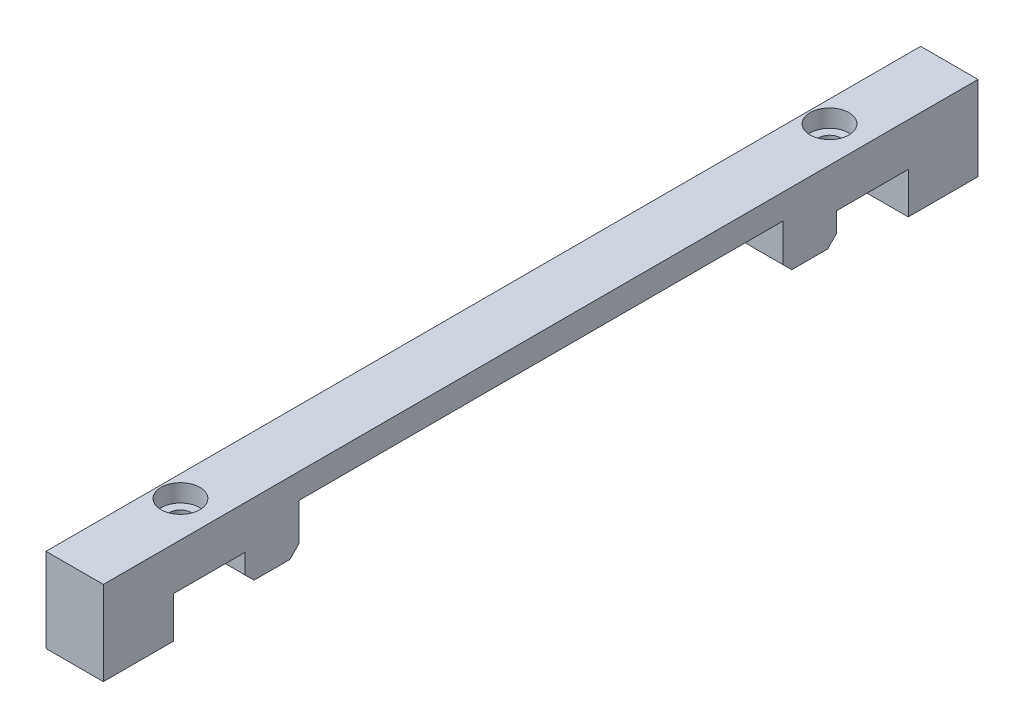
from build123d import *

# Parameters (mm, degrees)
SKETCH1_W                        = 8.128
SKETCH1_H                        = 127
BOSS_EXTRUDE1_DEPTH              = 18.288
SKETCH2_W                        = 8.128
SKETCH2_H                        = 104.14
CUT_EXTRUDE1_DEPTH               = 8.128
SKETCH4_W                        = 8.128
SKETCH4_H                        = 10.16
CUT_EXTRUDE2_DEPTH               = 4.064
SKETCH5_W                        = 8.128
SKETCH5_H                        = 34.29
CUT_EXTRUDE4_DEPTH               = 6.604
CBORE_FOR_M2_5_SHCS1_D           = 3.1
CBORE_FOR_M2_5_SHCS1_CBORE_D     = 5.5
CBORE_FOR_M2_5_SHCS1_CBORE_DEPTH = 2.5
CHAMFER1_SIZE                    = 1.27
SKETCH17_W                       = 8.128
SKETCH17_H                       = 127
CUT_EXTRUDE5_DEPTH               = 6.35
SKETCH18_W                       = 8.128
SKETCH18_H                       = 1.546440773
CUT_EXTRUDE6_DEPTH               = 12.938
SKETCH19_W                       = 8.128
SKETCH19_H                       = 1.507728281
CUT_EXTRUDE7_DEPTH               = 12.938


with BuildPart() as part:
    # Sketch1 → Boss-Extrude1 (new body)
    with BuildSketch(Plane(origin=(0, 0, 0), x_dir=(1, 0, 0), z_dir=(0, 1, 0))):
        Rectangle(SKETCH1_W, SKETCH1_H)
    extrude(amount=BOSS_EXTRUDE1_DEPTH)

    # Sketch2 → Cut-Extrude1 (cut)
    with BuildSketch(Plane.XZ):
        Rectangle(SKETCH2_W, SKETCH2_H)
    extrude(amount=-CUT_EXTRUDE1_DEPTH, mode=Mode.SUBTRACT)

    # Sketch4 → Cut-Extrude2 (cut)
    with BuildSketch(Plane.XZ.offset(-8.128)):
        with Locations((0, -46.99)):
            Rectangle(SKETCH4_W, SKETCH4_H)
    cut_extrude2 = extrude(amount=-CUT_EXTRUDE2_DEPTH, mode=Mode.SUBTRACT)

    # Sketch5 → Cut-Extrude4 (cut)
    with BuildSketch(Plane.XZ.offset(-8.128)):
        with Locations((0, -17.145)):
            Rectangle(SKETCH5_W, SKETCH5_H)
    cut_extrude4 = extrude(amount=-CUT_EXTRUDE4_DEPTH, mode=Mode.SUBTRACT)

    # CBORE for M2.5 SHCS1 (through all)
    with Locations(Plane(origin=(0, 18.288, 0), x_dir=(1, 0, 0), z_dir=(0, 1, 0))):
        with Locations((-1.016, 45.99)):
            cbore_for_m2_5_shcs1 = CounterBoreHole(CBORE_FOR_M2_5_SHCS1_D / 2, CBORE_FOR_M2_5_SHCS1_CBORE_D / 2, CBORE_FOR_M2_5_SHCS1_CBORE_DEPTH)

    # Mirror1: Cut-Extrude2, Cut-Extrude4 across plane
    add(cut_extrude2.mirror(Plane(origin=(4.064, 14.732, 0), x_dir=(1, 0, 0), z_dir=(0, 0, 1))), mode=Mode.SUBTRACT)
    add(cut_extrude4.mirror(Plane(origin=(4.064, 14.732, 0), x_dir=(1, 0, 0), z_dir=(0, 0, 1))), mode=Mode.SUBTRACT)

    # Mirror2: CBORE for M2.5 SHCS1 across plane
    add(cbore_for_m2_5_shcs1.mirror(Plane.XY), mode=Mode.SUBTRACT)

    # Sketch15 → Ø1.0mm Dowel Hole1 (revolve, cut)
    with BuildSketch(Plane(origin=(0, 0, -57.785), x_dir=(0, 0, -1), z_dir=(1, 0, 0))):
        Polygon((0, 0), (0, 11.94227264), (2.65, 10.349992), (2.65, 0), align=None)
    f_1_0mm_dowel_hole1 = revolve(axis=Axis((0, -6.35, -57.785), (0, 1, 0)), mode=Mode.SUBTRACT)

    # Mirror3: Ø1.0mm Dowel Hole1 across plane
    add(f_1_0mm_dowel_hole1.mirror(Plane.XY), mode=Mode.SUBTRACT)

    # Chamfer1
    chamfer1_edges = [part.edges().sort_by_distance(p)[0] for p in [
        (0, 0, 52.07),
        (0, 0, -52.07),
        (0, 8.128, -41.91),
        (0, 0, 63.5),
        (0, 8.128, -34.29),
        (0, 0, -63.5),
        (0, 8.128, 41.91),
        (0, 8.128, 34.29),
    ]]
    chamfer(chamfer1_edges, length=CHAMFER1_SIZE)

    # Sketch17 → Cut-Extrude5 (cut)
    with BuildSketch(Plane.XZ):
        Rectangle(SKETCH17_W, SKETCH17_H)
    extrude(amount=-CUT_EXTRUDE5_DEPTH, mode=Mode.SUBTRACT)

    # Sketch18 → Cut-Extrude6 (cut, through all)
    with BuildSketch(Plane.XZ.offset(-6.35)):
        with Locations((0, -62.726779614)):
            Rectangle(SKETCH18_W, SKETCH18_H)
    extrude(amount=-CUT_EXTRUDE6_DEPTH, mode=Mode.SUBTRACT)

    # Sketch19 → Cut-Extrude7 (cut, through all)
    with BuildSketch(Plane.XZ.offset(-6.35)):
        with Locations((0, 62.74613586)):
            Rectangle(SKETCH19_W, SKETCH19_H)
    extrude(amount=-CUT_EXTRUDE7_DEPTH, mode=Mode.SUBTRACT)


solid = part.part
